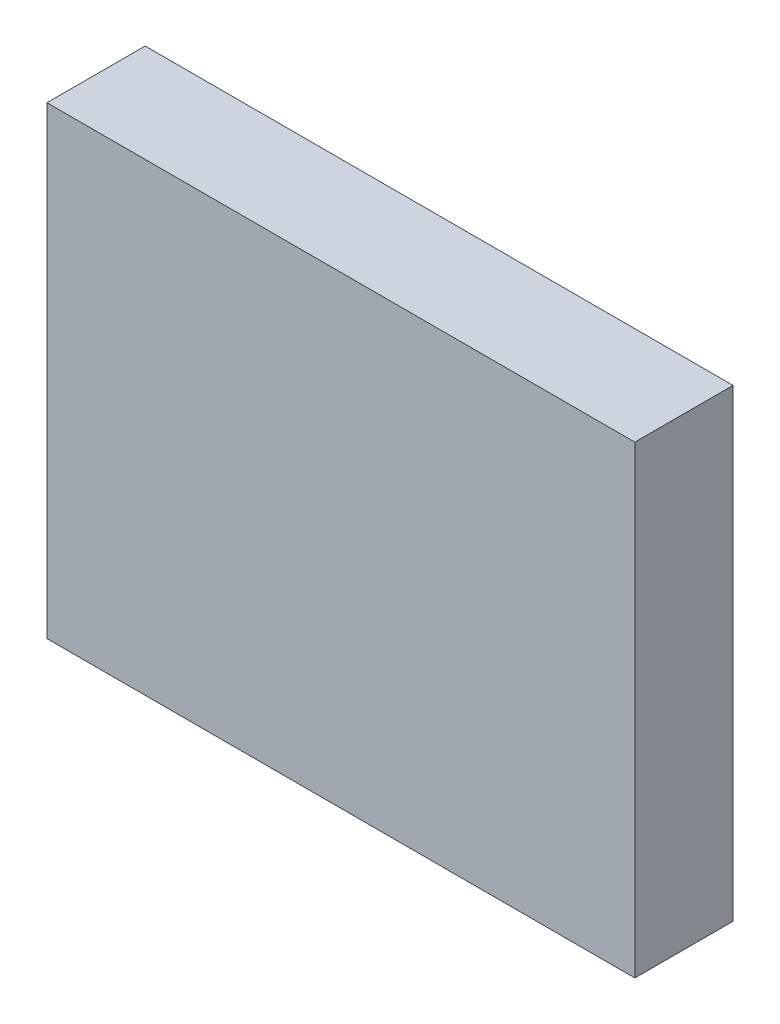
from build123d import *

# Parameters (mm, degrees)
CROQUIS1_W              = 38
CROQUIS1_H              = 30
SALIENTE_EXTRUIR1_DEPTH = 6.35


with BuildPart() as part:
    # Croquis1 → Saliente-Extruir1 (new body)
    with BuildSketch(Plane.XY):
        Rectangle(CROQUIS1_W, CROQUIS1_H)
    extrude(amount=SALIENTE_EXTRUIR1_DEPTH)


solid = part.part
